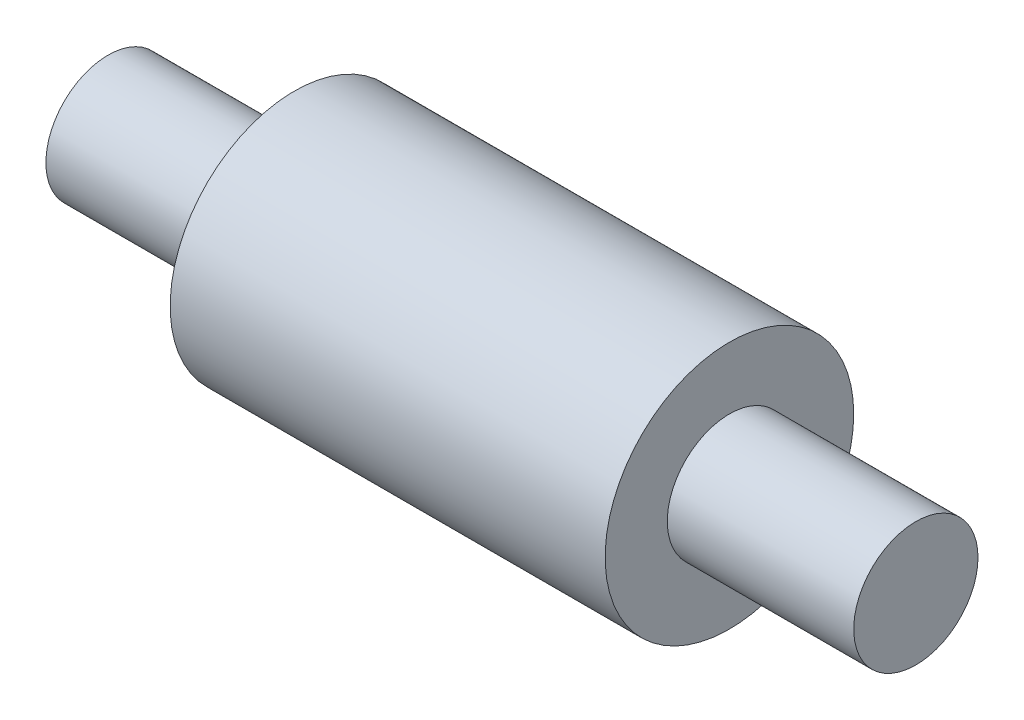
from build123d import *


with BuildPart() as part:
    # Sketch3 → Revolve1 (revolve)
    with BuildSketch(Plane(origin=(0, 0, 0), x_dir=(1, 0, 0), z_dir=(0, 1, 0))):
        Polygon((-56.016573024, 0), (-56.016573024, 10), (-26.016573024, 10), (-26.016573024, 20), (43.983426976, 20), (43.983426976, 10), (73.983426976, 10), (73.983426976, 0), align=None)
    revolve(axis=Axis((0, 0, 0), (-1, 0, 0)))


solid = part.part
